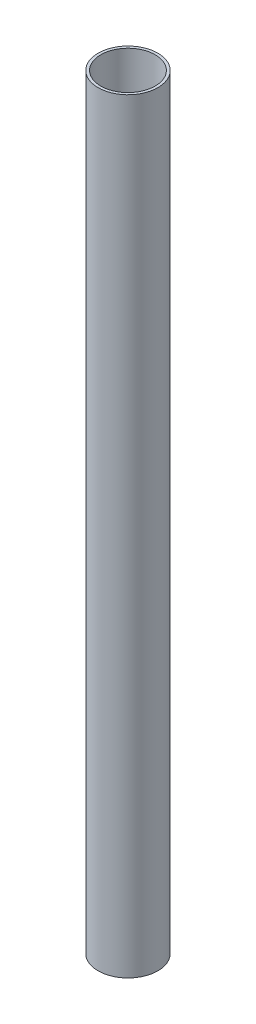
from build123d import *

# Parameters (mm, degrees)
SKETCH1_R           = 7.9375
SKETCH1_R_2         = 7.2263
BOSS_EXTRUDE1_DEPTH = 203.2


with BuildPart() as part:
    # Sketch1 → Boss-Extrude1 (new body)
    with BuildSketch(Plane(origin=(0, 0, 0), x_dir=(1, 0, 0), z_dir=(0, 1, 0))):
        Circle(SKETCH1_R)
        Circle(SKETCH1_R_2, mode=Mode.SUBTRACT)
    extrude(amount=BOSS_EXTRUDE1_DEPTH)


solid = part.part
